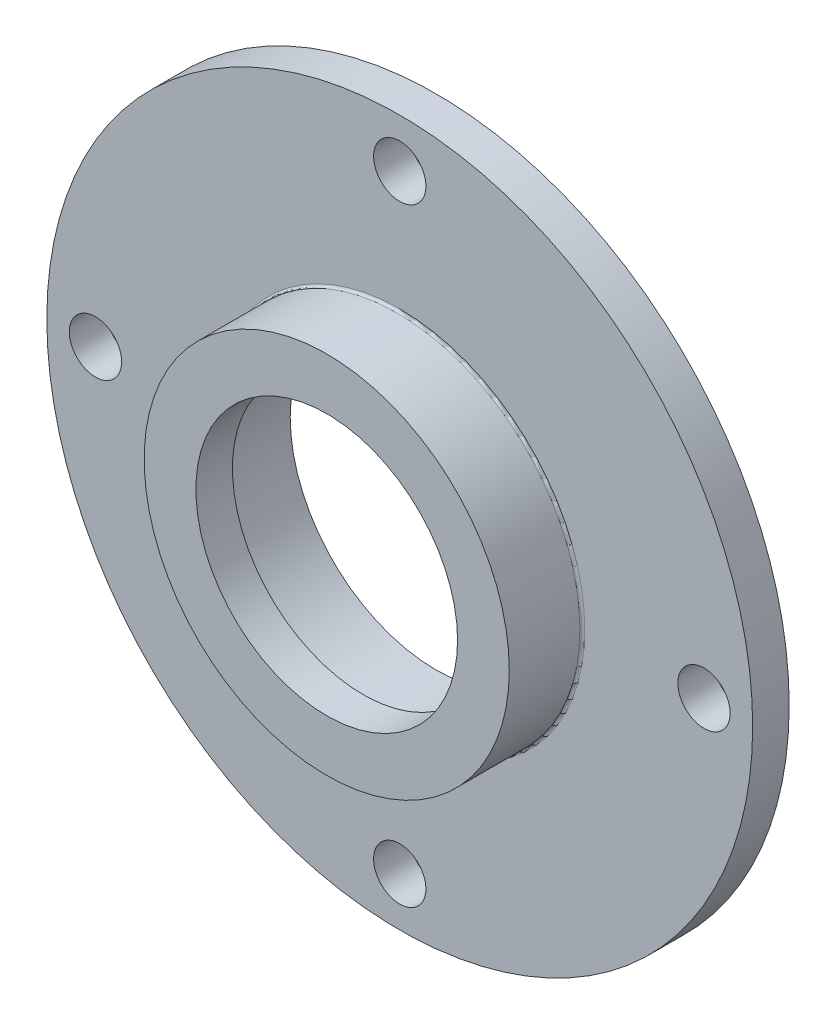
from build123d import *

# Parameters (mm, degrees)
SKETCH1_R            = 29
SKETCH1_R_2          = 12
BOSS_EXTRUDE1_DEPTH  = 3
SKETCH2_R            = 15
SKETCH2_R_2          = 12
BOSS_EXTRUDE2_DEPTH  = 6
SKETCH3_R            = 15
SKETCH3_R_2          = 10.75
BOSS_EXTRUDE3_DEPTH  = 3
M4_CLEARANCE_HOLE1_D = 4.3
FILLET1_R            = 0.2


with BuildPart() as part:
    # Sketch1 → Boss-Extrude1 (new body)
    with BuildSketch(Plane.XY):
        Circle(SKETCH1_R)
        Circle(SKETCH1_R_2, mode=Mode.SUBTRACT)
    extrude(amount=BOSS_EXTRUDE1_DEPTH)

    # Sketch2 → Boss-Extrude2 (add)
    with BuildSketch(Plane.XY.offset(3)):
        Circle(SKETCH2_R)
        Circle(SKETCH2_R_2, mode=Mode.SUBTRACT)
    extrude(amount=BOSS_EXTRUDE2_DEPTH)

    # Sketch3 → Boss-Extrude3 (add)
    with BuildSketch(Plane.XY.offset(9)):
        Circle(SKETCH3_R)
        Circle(SKETCH3_R_2, mode=Mode.SUBTRACT)
    extrude(amount=-BOSS_EXTRUDE3_DEPTH)

    # M4 Clearance Hole1 (through all)
    with Locations(Plane.XY.offset(3)):
        with Locations((0, 25), (25, 0), (0, -25), (-25, 0), (0, 0)):
            Hole(M4_CLEARANCE_HOLE1_D / 2)

    # Fillet1
    fillet1_edges = [part.edges().sort_by_distance(p)[0] for p in [
        (-15, 0, 3),
        (-12, 0, 6),
    ]]
    fillet(fillet1_edges, radius=FILLET1_R)


solid = part.part
